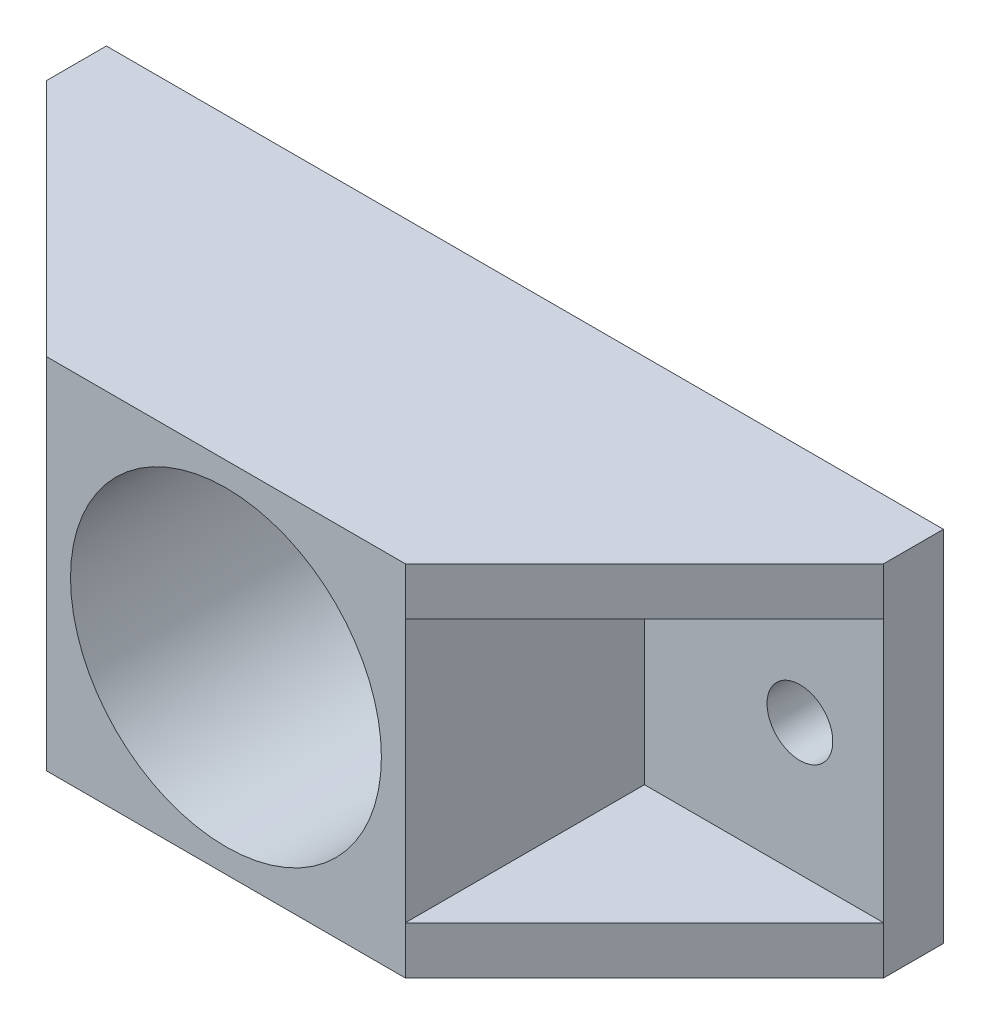
from build123d import *

# Parameters (mm, degrees)
SKETCH_1_W          = 70
SKETCH_1_H          = 30
SKETCH_1_R          = 2.75
EXTRUDE_1_DEPTH     = 5
SKETCH_2_W          = 30
SKETCH_2_H          = 30
EXTRUDE_2_DEPTH     = 20
SKETCH_3_R          = 13
CUT_EXTRUDE_1_DEPTH = 26
EXTRUDE_3_DEPTH     = 4


with BuildPart() as part:
    # 草图1 → 凸台-拉伸1 (new body)
    with BuildSketch(Plane.XY):
        Rectangle(SKETCH_1_W, SKETCH_1_H)
        with Locations((-28, 0)):
            Circle(SKETCH_1_R, mode=Mode.SUBTRACT)
        with Locations((28, 0)):
            Circle(SKETCH_1_R, mode=Mode.SUBTRACT)
    extrude(amount=EXTRUDE_1_DEPTH)

    # 草图2 → 凸台-拉伸2 (add)
    with BuildSketch(Plane.XY.offset(5)):
        Rectangle(SKETCH_2_W, SKETCH_2_H)
    extrude(amount=EXTRUDE_2_DEPTH)

    # 草图3 → 切除-拉伸1 (cut, through all)
    with BuildSketch(Plane.XY.offset(25)):
        Circle(SKETCH_3_R)
    extrude(amount=-CUT_EXTRUDE_1_DEPTH, mode=Mode.SUBTRACT)

    # 草图4 → 凸台-拉伸3 (add)
    with BuildSketch(Plane.XZ.offset(15)):
        Polygon((-15, 25), (-35, 5), (-15, 5), align=None)
        Polygon((15, 25), (15, 5), (35, 5), align=None)
    extrude_3 = extrude(amount=-EXTRUDE_3_DEPTH)

    # 镜向1: 凸台-拉伸3 across plane
    add(extrude_3.mirror(Plane.ZX))


solid = part.part
